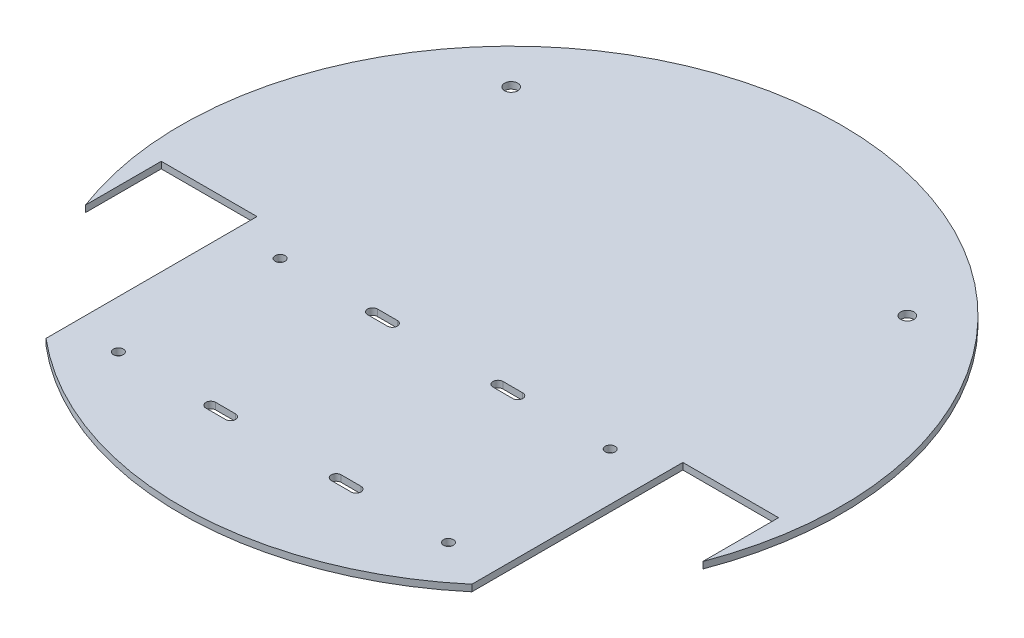
from build123d import *

# Parameters (mm, degrees)
SKETCH1_R           = 1.5
SKETCH1_R_2         = 2
BOSS_EXTRUDE1_DEPTH = 2


with BuildPart() as part:
    # Sketch1 → Boss-Extrude1 (new body)
    with BuildSketch(Plane(origin=(0, 0, 0), x_dir=(1, 0, 0), z_dir=(0, 1, 0))):
        with BuildLine():
            Line((-93.5, -35.464771253), (-93.5, -12.5))
            Line((-93.5, -12.5), (-64.5, -12.5))
            Line((-64.5, -12.5), (-64.5, -76.418256981))
            ThreePointArc((-64.5, -76.418256981), (0, -100), (64.5, -76.418256981))
            Line((64.5, -76.418256981), (64.5, -12.5))
            Line((64.5, -12.5), (93.5, -12.5))
            Line((93.5, -12.5), (93.5, -35.464771253))
            ThreePointArc((93.5, -35.464771253), (0, 100), (-93.5, -35.464771253))
        make_face()
        with Locations((-50, -69)):
            Circle(SKETCH1_R, mode=Mode.SUBTRACT)
        with BuildLine():
            Line((-22, -67.5), (-16, -67.5))
            ThreePointArc((-16, -67.5), (-14.5, -69), (-16, -70.5))
            Line((-16, -70.5), (-22, -70.5))
            ThreePointArc((-22, -70.5), (-23.5, -69), (-22, -67.5))
        make_face(mode=Mode.SUBTRACT)
        with Locations((-50, -20)):
            Circle(SKETCH1_R, mode=Mode.SUBTRACT)
        with BuildLine():
            ThreePointArc((-16, -18.5), (-14.5, -20), (-16, -21.5))
            Line((-16, -21.5), (-22, -21.5))
            ThreePointArc((-22, -21.5), (-23.5, -20), (-22, -18.5))
            Line((-22, -18.5), (-16, -18.5))
        make_face(mode=Mode.SUBTRACT)
        with BuildLine():
            ThreePointArc((16, -70.5), (14.5, -69), (16, -67.5))
            Line((16, -67.5), (22, -67.5))
            ThreePointArc((22, -67.5), (23.5, -69), (22, -70.5))
            Line((22, -70.5), (16, -70.5))
        make_face(mode=Mode.SUBTRACT)
        with Locations((50, -69)):
            Circle(SKETCH1_R, mode=Mode.SUBTRACT)
        with BuildLine():
            Line((22, -21.5), (16, -21.5))
            ThreePointArc((16, -21.5), (14.5, -20), (16, -18.5))
            Line((16, -18.5), (22, -18.5))
            ThreePointArc((22, -18.5), (23.5, -20), (22, -21.5))
        make_face(mode=Mode.SUBTRACT)
        with Locations((50, -20)):
            Circle(SKETCH1_R, mode=Mode.SUBTRACT)
        with Locations((-60, 60)):
            Circle(SKETCH1_R_2, mode=Mode.SUBTRACT)
        with Locations((60, 60)):
            Circle(SKETCH1_R_2, mode=Mode.SUBTRACT)
    extrude(amount=BOSS_EXTRUDE1_DEPTH)


solid = part.part
